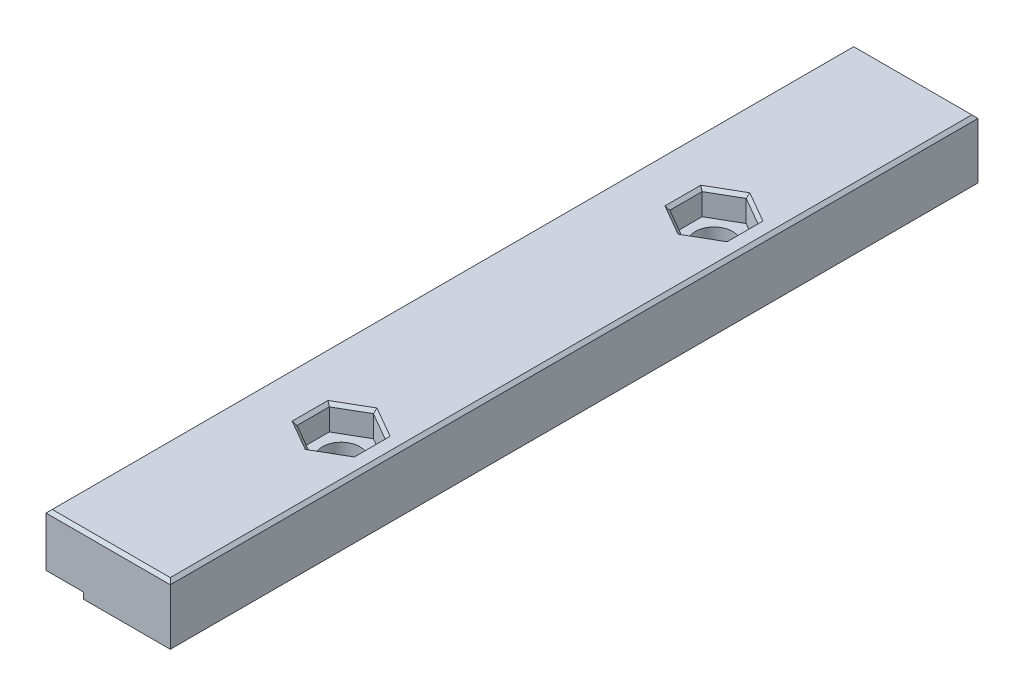
from build123d import *

# Parameters (mm, degrees)
SKETCH1_W           = 20
SKETCH1_H           = 10
BOSS_EXTRUDE1_DEPTH = 130
SKETCH2_R           = 3
CUT_EXTRUDE1_DEPTH  = 140
CUT_EXTRUDE2_DEPTH  = 4
LPATTERN1_COUNT     = 2
LPATTERN1_PITCH     = 60
SKETCH4_W           = 6
SKETCH4_H           = 1.5
CUT_EXTRUDE3_DEPTH  = 200
CHAMFER1_SIZE       = 0.5


with BuildPart() as part:
    # Sketch1 → Boss-Extrude1 (new body)
    with BuildSketch(Plane.XY):
        with Locations((10, 15.187969925)):
            Rectangle(SKETCH1_W, SKETCH1_H)
    extrude(amount=BOSS_EXTRUDE1_DEPTH)

    # Sketch2 → Cut-Extrude1 (cut)
    with BuildSketch(Plane(origin=(0, 20.187969925, 0), x_dir=(1, 0, 0), z_dir=(0, 1, 0))):
        with Locations((12.5, -35)):
            Circle(SKETCH2_R)
    cut_extrude1 = extrude(amount=-CUT_EXTRUDE1_DEPTH, mode=Mode.SUBTRACT)

    # Sketch3 → Cut-Extrude2 (cut)
    with BuildSketch(Plane(origin=(0, 20.187969925, 0), x_dir=(1, 0, 0), z_dir=(0, 1, 0))):
        Polygon((12.5, -29.803847577), (8, -32.401923789), (8, -37.598076211), (12.5, -40.196152423), (17, -37.598076211), (17, -32.401923789), align=None)
    cut_extrude2 = extrude(amount=-CUT_EXTRUDE2_DEPTH, mode=Mode.SUBTRACT)

    # LPattern1: Cut-Extrude1, Cut-Extrude2 ×2
    with Locations(*[(0, 0, i * LPATTERN1_PITCH) for i in range(1, LPATTERN1_COUNT)]):
        add(cut_extrude1, mode=Mode.SUBTRACT)
        add(cut_extrude2, mode=Mode.SUBTRACT)

    # Sketch4 → Cut-Extrude3 (cut)
    with BuildSketch(Plane(origin=(0, 0, 0), x_dir=(-1, 0, 0), z_dir=(0, 0, -1))):
        with Locations((-3, 10.937969925)):
            Rectangle(SKETCH4_W, SKETCH4_H)
    extrude(amount=-CUT_EXTRUDE3_DEPTH, mode=Mode.SUBTRACT)

    # Chamfer1
    chamfer1_edges = [part.edges().sort_by_distance(p)[0] for p in [
        (9.5, 10.187969925, 35),
        (14.75, 20.187969925, 31.102885683),
        (10.25, 20.187969925, 31.102885683),
        (8, 20.187969925, 35),
        (10.25, 20.187969925, 38.897114317),
        (14.75, 20.187969925, 38.897114317),
        (17, 20.187969925, 35),
        (9.5, 10.187969925, 95),
        (14.75, 20.187969925, 91.102885683),
        (10.25, 20.187969925, 91.102885683),
        (8, 20.187969925, 95),
        (10.25, 20.187969925, 98.897114317),
        (14.75, 20.187969925, 98.897114317),
        (17, 20.187969925, 95),
        (10, 20.187969925, 0),
        (13, 10.187969925, 0),
        (13, 10.187969925, 130),
        (6, 10.187969925, 65),
        (20, 10.187969925, 65),
        (0, 20.187969925, 65),
        (20, 20.187969925, 65),
        (10, 20.187969925, 130),
    ]]
    chamfer(chamfer1_edges, length=CHAMFER1_SIZE)


solid = part.part
